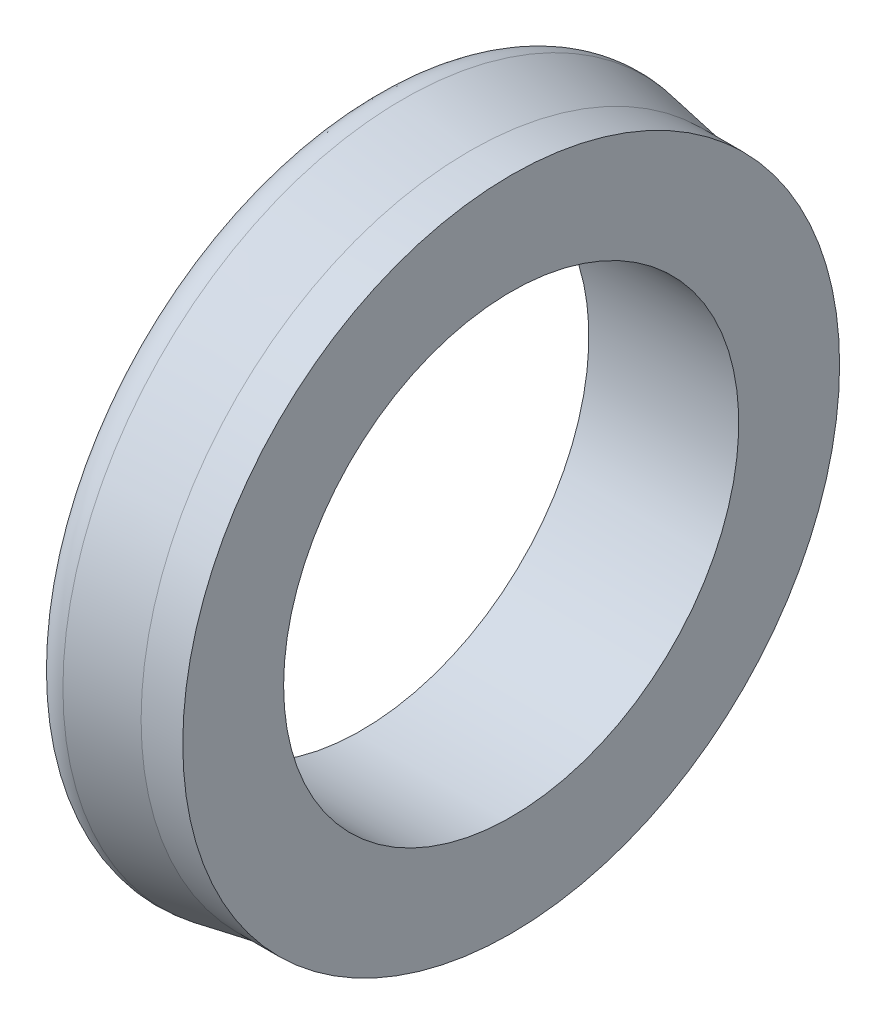
from build123d import *


with BuildPart() as part:
    # Esquisse1 → Base-Révolution (revolve)
    with BuildSketch(Plane.XY, mode=Mode.PRIVATE) as base_r_volution_sk:
        with BuildLine():
            Line((0, 8.35), (5.5, 8.35))
            Line((5.5, 8.35), (5.5, 12.05))
            Line((5.5, 12.05), (3.97133627, 12.05))
            Line((3.97133627, 12.05), (1.536555322, 12.484450765))
            ThreePointArc((1.536555322, 12.484450765), (1.023585598, 12.441393987), (0.6, 12.148875499))
            Line((0.6, 12.148875499), (0.5, 11.348875499))
            Line((0.5, 11.348875499), (2.77026429, 10.943780306))
            ThreePointArc((2.77026429, 10.943780306), (3.098442042, 10.514730484), (2.7, 10.15))
            Line((2.7, 10.15), (0, 10.15))
            Line((0, 10.15), (0, 8.35))
        make_face()
    revolve(base_r_volution_sk.sketch.rotate(Axis((-5, 0, 0), (1, 0, 0)), 90), axis=Axis((-5, 0, 0), (1, 0, 0)))  # turned: the seam where the file's is


solid = part.part
